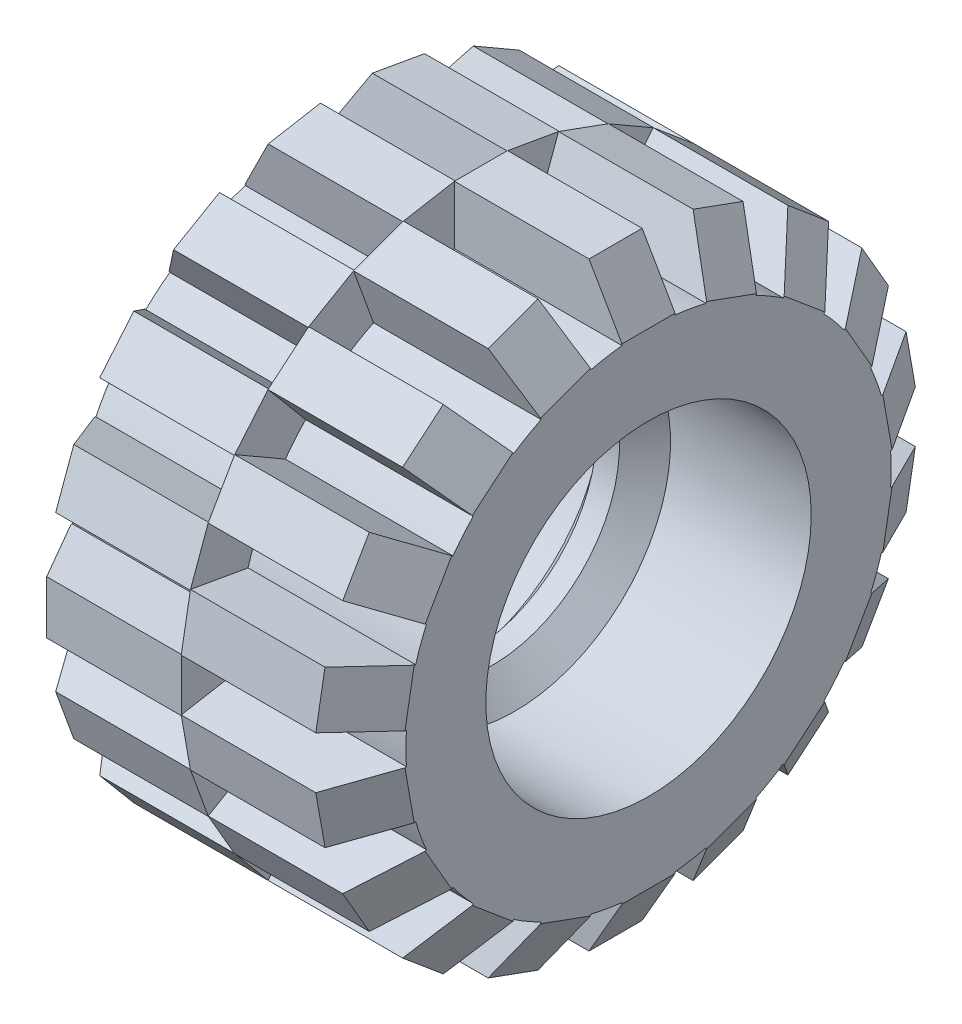
from build123d import *
from OCP.BRepFilletAPI import BRepFilletAPI_MakeChamfer

# Parameters (mm, degrees)
EXTRUDE1_DEPTH                = 5.87
EXTRUDE1_DEPTH_BACK           = 5.87
SKETCH1_R                     = 8.5
SKETCH1_R_2                   = 5.7
EXTRUDE2_START                = 7
SKETCH2_W                     = 5.87
SKETCH2_H                     = 1.86
EXTRUDE2_DEPTH                = 3.5
EXTRUDE3_START                = 7
SKETCH4_W                     = 5.87
SKETCH4_H                     = 1.86
EXTRUDE3_DEPTH                = 3.5
CHAMFER1_SIZE                 = 2
CHAMFER1_SIZE2                = 1.154700538
CIRPATTERN3_COUNT             = 18
CHAMFER1_OF_CIRPATTERN3_SIZE  = 2
CHAMFER1_OF_CIRPATTERN3_SIZE2 = 1.154700538


with BuildPart() as part:
    # Sketch1 → Extrude1 (new, two sides: drawn at the far end of the back side and taken through both)
    with BuildSketch(Plane(origin=(0, 0, 0), x_dir=(0, 0, -1), z_dir=(1, 0, 0)).offset(-EXTRUDE1_DEPTH_BACK)):
        Circle(SKETCH1_R)
        Circle(SKETCH1_R_2, mode=Mode.SUBTRACT)
    extrude(amount=EXTRUDE1_DEPTH + EXTRUDE1_DEPTH_BACK)

    # Sketch2 → Extrude2 (add)
    with BuildSketch(Plane(origin=(0, 0, 0), x_dir=(1, 0, 0), z_dir=(0, 1, 0)).offset(EXTRUDE2_START)):
        with Locations((2.935, 0)):
            Rectangle(SKETCH2_W, SKETCH2_H)
    extrude2 = extrude(amount=EXTRUDE2_DEPTH)

    # Sketch4 → Extrude3 (add)
    with BuildSketch(Plane.XY.offset(EXTRUDE3_START)):
        with Locations((-2.935, 0)):
            Rectangle(SKETCH4_W, SKETCH4_H)
    extrude3 = extrude(amount=EXTRUDE3_DEPTH)

    # Chamfer1: one chamfer whose edges measure the first distance from different faces: ONE call of the kernel's chamfer builder (chamfer() names one face for all edges)
    chamfer1_edges_1 = [part.edges().sort_by_distance(p)[0] for p in [
        (-5.87, 0, 10.5),
    ]]
    chamfer1_side_1 = [part.faces().sort_by_distance(p)[0] for p in [
        (-5.87, -8.232664961, -0.451731182),
    ]]
    chamfer1_edges_2 = [part.edges().sort_by_distance(p)[0] for p in [
        (5.87, 10.5, 0),
    ]]
    chamfer1_side_2 = [part.faces().sort_by_distance(p)[0] for p in [
        (5.87, -6.140795403, 5.501951039),
    ]]
    chamfer1 = BRepFilletAPI_MakeChamfer(part.part.solid().wrapped)
    for e in chamfer1_edges_1:
        chamfer1.Add(CHAMFER1_SIZE, CHAMFER1_SIZE2, e.wrapped, chamfer1_side_1[0].wrapped)  # the first distance lies on this face
    for e in chamfer1_edges_2:
        chamfer1.Add(CHAMFER1_SIZE, CHAMFER1_SIZE2, e.wrapped, chamfer1_side_2[0].wrapped)  # the first distance lies on this face
    add(Compound.cast(chamfer1.Shape()), mode=Mode.REPLACE)

    # CirPattern3: Extrude2, Extrude3 ×18 about axis
    cirpattern3_axis = Axis((-5.87, 0, 0), (1, 0, 0))
    add([extrude2.rotate(cirpattern3_axis, i * 360 / CIRPATTERN3_COUNT) for i in range(1, CIRPATTERN3_COUNT)])
    add([extrude3.rotate(cirpattern3_axis, i * 360 / CIRPATTERN3_COUNT) for i in range(1, CIRPATTERN3_COUNT)])

    # Chamfer1 of CirPattern3: one chamfer whose edges measure the first distance from different faces: ONE call of the kernel's chamfer builder (chamfer() names one face for all edges)
    chamfer1_of_cirpattern3_edges_1 = [part.edges().sort_by_distance(p)[0] for p in [
        (-5.87, -3.591211505, 9.866772518),
    ]]
    chamfer1_of_cirpattern3_side_1 = [part.faces().sort_by_distance(p)[0] for p in [
        (-5.87, -7.581673349, -3.240225708),
    ]]
    chamfer1_of_cirpattern3_edges_2 = [part.edges().sort_by_distance(p)[0] for p in [
        (5.87, 9.866772518, 3.591211505),
    ]]
    chamfer1_of_cirpattern3_side_2 = [part.faces().sort_by_distance(p)[0] for p in [
        (5.87, -7.652238209, 3.069867067),
    ]]
    chamfer1_of_cirpattern3_edges_3 = [part.edges().sort_by_distance(p)[0] for p in [
        (-5.87, -6.749269902, 8.043466653),
    ]]
    chamfer1_of_cirpattern3_side_3 = [part.faces().sort_by_distance(p)[0] for p in [
        (-5.87, -6.016220038, -5.637901193),
    ]]
    chamfer1_of_cirpattern3_edges_4 = [part.edges().sort_by_distance(p)[0] for p in [
        (5.87, 8.043466653, 6.749269902),
    ]]
    chamfer1_of_cirpattern3_side_4 = [part.faces().sort_by_distance(p)[0] for p in [
        (5.87, -8.240708152, 0.267511821),
    ]]
    chamfer1_of_cirpattern3_edges_5 = [part.edges().sort_by_distance(p)[0] for p in [
        (-5.87, -9.09326674, 5.25),
    ]]
    chamfer1_of_cirpattern3_side_5 = [part.faces().sort_by_distance(p)[0] for p in [
        (-5.87, -3.725121801, -7.355562588),
    ]]
    chamfer1_of_cirpattern3_edges_6 = [part.edges().sort_by_distance(p)[0] for p in [
        (5.87, 5.25, 9.09326674),
    ]]
    chamfer1_of_cirpattern3_side_6 = [part.faces().sort_by_distance(p)[0] for p in [
        (5.87, -7.835227071, -2.567109299),
    ]]
    chamfer1_of_cirpattern3_edges_7 = [part.edges().sort_by_distance(p)[0] for p in [
        (-5.87, -10.340481407, 1.823305866),
    ]]
    chamfer1_of_cirpattern3_side_7 = [part.faces().sort_by_distance(p)[0] for p in [
        (-5.87, -0.984718897, -8.186034578),
    ]]
    chamfer1_of_cirpattern3_edges_8 = [part.edges().sort_by_distance(p)[0] for p in [
        (5.87, 1.823305866, 10.340481407),
    ]]
    chamfer1_of_cirpattern3_side_8 = [part.faces().sort_by_distance(p)[0] for p in [
        (5.87, -6.484701971, -5.092099151),
    ]]
    chamfer1_of_cirpattern3_edges_9 = [part.edges().sort_by_distance(p)[0] for p in [
        (-5.87, -10.340481407, -1.823305866),
    ]]
    chamfer1_of_cirpattern3_side_9 = [part.faces().sort_by_distance(p)[0] for p in [
        (-5.87, 1.874455638, -8.029149985),
    ]]
    chamfer1_of_cirpattern3_edges_10 = [part.edges().sort_by_distance(p)[0] for p in [
        (5.87, -1.823305866, 10.340481407),
    ]]
    chamfer1_of_cirpattern3_side_10 = [part.faces().sort_by_distance(p)[0] for p in [
        (5.87, -4.352026108, -7.002906694),
    ]]
    chamfer1_of_cirpattern3_edges_11 = [part.edges().sort_by_distance(p)[0] for p in [
        (-5.87, -9.09326674, -5.25),
    ]]
    chamfer1_of_cirpattern3_side_11 = [part.faces().sort_by_distance(p)[0] for p in [
        (-5.87, 4.50754316, -6.903831406),
    ]]
    chamfer1_of_cirpattern3_edges_12 = [part.edges().sort_by_distance(p)[0] for p in [
        (5.87, -5.25, 9.09326674),
    ]]
    chamfer1_of_cirpattern3_side_12 = [part.faces().sort_by_distance(p)[0] for p in [
        (5.87, -1.694431668, -8.069060338),
    ]]
    chamfer1_of_cirpattern3_edges_13 = [part.edges().sort_by_distance(p)[0] for p in [
        (-5.87, -6.749269902, -8.043466653),
    ]]
    chamfer1_of_cirpattern3_side_13 = [part.faces().sort_by_distance(p)[0] for p in [
        (-5.87, 6.596954452, -4.945808869),
    ]]
    chamfer1_of_cirpattern3_edges_14 = [part.edges().sort_by_distance(p)[0] for p in [
        (5.87, -8.043466653, 6.749269902),
    ]]
    chamfer1_of_cirpattern3_side_14 = [part.faces().sort_by_distance(p)[0] for p in [
        (5.87, 1.167536238, -8.161966218),
    ]]
    chamfer1_of_cirpattern3_edges_15 = [part.edges().sort_by_distance(p)[0] for p in [
        (-5.87, -3.591211505, -9.866772518),
    ]]
    chamfer1_of_cirpattern3_side_15 = [part.faces().sort_by_distance(p)[0] for p in [
        (-5.87, 7.890675676, -2.391248791),
    ]]
    chamfer1_of_cirpattern3_edges_16 = [part.edges().sort_by_distance(p)[0] for p in [
        (5.87, -9.866772518, 3.591211505),
    ]]
    chamfer1_of_cirpattern3_side_16 = [part.faces().sort_by_distance(p)[0] for p in [
        (5.87, 3.888682043, -7.270418515),
    ]]
    chamfer1_of_cirpattern3_edges_17 = [part.edges().sort_by_distance(p)[0] for p in [
        (-5.87, 0, -10.5),
    ]]
    chamfer1_of_cirpattern3_side_17 = [part.faces().sort_by_distance(p)[0] for p in [
        (-5.87, 8.232664961, 0.451731182),
    ]]
    chamfer1_of_cirpattern3_edges_18 = [part.edges().sort_by_distance(p)[0] for p in [
        (5.87, -10.5, 0),
    ]]
    chamfer1_of_cirpattern3_side_18 = [part.faces().sort_by_distance(p)[0] for p in [
        (5.87, 6.140795403, -5.501951039),
    ]]
    chamfer1_of_cirpattern3_edges_19 = [part.edges().sort_by_distance(p)[0] for p in [
        (-5.87, 3.591211505, -9.866772518),
    ]]
    chamfer1_of_cirpattern3_side_19 = [part.faces().sort_by_distance(p)[0] for p in [
        (-5.87, 7.581673349, 3.240225708),
    ]]
    chamfer1_of_cirpattern3_edges_20 = [part.edges().sort_by_distance(p)[0] for p in [
        (5.87, -9.866772518, -3.591211505),
    ]]
    chamfer1_of_cirpattern3_side_20 = [part.faces().sort_by_distance(p)[0] for p in [
        (5.87, 7.652238209, -3.069867067),
    ]]
    chamfer1_of_cirpattern3_edges_21 = [part.edges().sort_by_distance(p)[0] for p in [
        (-5.87, 6.749269902, -8.043466653),
    ]]
    chamfer1_of_cirpattern3_side_21 = [part.faces().sort_by_distance(p)[0] for p in [
        (-5.87, 6.016220038, 5.637901193),
    ]]
    chamfer1_of_cirpattern3_edges_22 = [part.edges().sort_by_distance(p)[0] for p in [
        (5.87, -8.043466653, -6.749269902),
    ]]
    chamfer1_of_cirpattern3_side_22 = [part.faces().sort_by_distance(p)[0] for p in [
        (5.87, 8.240708152, -0.267511821),
    ]]
    chamfer1_of_cirpattern3_edges_23 = [part.edges().sort_by_distance(p)[0] for p in [
        (-5.87, 9.09326674, -5.25),
    ]]
    chamfer1_of_cirpattern3_side_23 = [part.faces().sort_by_distance(p)[0] for p in [
        (-5.87, 3.725121801, 7.355562588),
    ]]
    chamfer1_of_cirpattern3_edges_24 = [part.edges().sort_by_distance(p)[0] for p in [
        (5.87, -5.25, -9.09326674),
    ]]
    chamfer1_of_cirpattern3_side_24 = [part.faces().sort_by_distance(p)[0] for p in [
        (5.87, 7.835227071, 2.567109299),
    ]]
    chamfer1_of_cirpattern3_edges_25 = [part.edges().sort_by_distance(p)[0] for p in [
        (-5.87, 10.340481407, -1.823305866),
    ]]
    chamfer1_of_cirpattern3_side_25 = [part.faces().sort_by_distance(p)[0] for p in [
        (-5.87, 0.984718897, 8.186034578),
    ]]
    chamfer1_of_cirpattern3_edges_26 = [part.edges().sort_by_distance(p)[0] for p in [
        (5.87, -1.823305866, -10.340481407),
    ]]
    chamfer1_of_cirpattern3_side_26 = [part.faces().sort_by_distance(p)[0] for p in [
        (5.87, 6.484701971, 5.092099151),
    ]]
    chamfer1_of_cirpattern3_edges_27 = [part.edges().sort_by_distance(p)[0] for p in [
        (-5.87, 10.340481407, 1.823305866),
    ]]
    chamfer1_of_cirpattern3_side_27 = [part.faces().sort_by_distance(p)[0] for p in [
        (-5.87, -1.874455638, 8.029149985),
    ]]
    chamfer1_of_cirpattern3_edges_28 = [part.edges().sort_by_distance(p)[0] for p in [
        (5.87, 1.823305866, -10.340481407),
    ]]
    chamfer1_of_cirpattern3_side_28 = [part.faces().sort_by_distance(p)[0] for p in [
        (5.87, 4.352026108, 7.002906694),
    ]]
    chamfer1_of_cirpattern3_edges_29 = [part.edges().sort_by_distance(p)[0] for p in [
        (-5.87, 9.09326674, 5.25),
    ]]
    chamfer1_of_cirpattern3_side_29 = [part.faces().sort_by_distance(p)[0] for p in [
        (-5.87, -4.50754316, 6.903831406),
    ]]
    chamfer1_of_cirpattern3_edges_30 = [part.edges().sort_by_distance(p)[0] for p in [
        (5.87, 5.25, -9.09326674),
    ]]
    chamfer1_of_cirpattern3_side_30 = [part.faces().sort_by_distance(p)[0] for p in [
        (5.87, 1.694431668, 8.069060338),
    ]]
    chamfer1_of_cirpattern3_edges_31 = [part.edges().sort_by_distance(p)[0] for p in [
        (-5.87, 6.749269902, 8.043466653),
    ]]
    chamfer1_of_cirpattern3_side_31 = [part.faces().sort_by_distance(p)[0] for p in [
        (-5.87, -6.596954452, 4.945808869),
    ]]
    chamfer1_of_cirpattern3_edges_32 = [part.edges().sort_by_distance(p)[0] for p in [
        (5.87, 8.043466653, -6.749269902),
    ]]
    chamfer1_of_cirpattern3_side_32 = [part.faces().sort_by_distance(p)[0] for p in [
        (5.87, -1.167536238, 8.161966218),
    ]]
    chamfer1_of_cirpattern3_edges_33 = [part.edges().sort_by_distance(p)[0] for p in [
        (-5.87, 3.591211505, 9.866772518),
    ]]
    chamfer1_of_cirpattern3_side_33 = [part.faces().sort_by_distance(p)[0] for p in [
        (-5.87, -7.890675676, 2.391248791),
    ]]
    chamfer1_of_cirpattern3_edges_34 = [part.edges().sort_by_distance(p)[0] for p in [
        (5.87, 9.866772518, -3.591211505),
    ]]
    chamfer1_of_cirpattern3_side_34 = [part.faces().sort_by_distance(p)[0] for p in [
        (5.87, -3.888682043, 7.270418515),
    ]]
    chamfer1_of_cirpattern3 = BRepFilletAPI_MakeChamfer(part.part.solid().wrapped)
    for e in chamfer1_of_cirpattern3_edges_1:
        chamfer1_of_cirpattern3.Add(CHAMFER1_OF_CIRPATTERN3_SIZE, CHAMFER1_OF_CIRPATTERN3_SIZE2, e.wrapped, chamfer1_of_cirpattern3_side_1[0].wrapped)  # the first distance lies on this face
    for e in chamfer1_of_cirpattern3_edges_2:
        chamfer1_of_cirpattern3.Add(CHAMFER1_OF_CIRPATTERN3_SIZE, CHAMFER1_OF_CIRPATTERN3_SIZE2, e.wrapped, chamfer1_of_cirpattern3_side_2[0].wrapped)  # the first distance lies on this face
    for e in chamfer1_of_cirpattern3_edges_3:
        chamfer1_of_cirpattern3.Add(CHAMFER1_OF_CIRPATTERN3_SIZE, CHAMFER1_OF_CIRPATTERN3_SIZE2, e.wrapped, chamfer1_of_cirpattern3_side_3[0].wrapped)  # the first distance lies on this face
    for e in chamfer1_of_cirpattern3_edges_4:
        chamfer1_of_cirpattern3.Add(CHAMFER1_OF_CIRPATTERN3_SIZE, CHAMFER1_OF_CIRPATTERN3_SIZE2, e.wrapped, chamfer1_of_cirpattern3_side_4[0].wrapped)  # the first distance lies on this face
    for e in chamfer1_of_cirpattern3_edges_5:
        chamfer1_of_cirpattern3.Add(CHAMFER1_OF_CIRPATTERN3_SIZE, CHAMFER1_OF_CIRPATTERN3_SIZE2, e.wrapped, chamfer1_of_cirpattern3_side_5[0].wrapped)  # the first distance lies on this face
    for e in chamfer1_of_cirpattern3_edges_6:
        chamfer1_of_cirpattern3.Add(CHAMFER1_OF_CIRPATTERN3_SIZE, CHAMFER1_OF_CIRPATTERN3_SIZE2, e.wrapped, chamfer1_of_cirpattern3_side_6[0].wrapped)  # the first distance lies on this face
    for e in chamfer1_of_cirpattern3_edges_7:
        chamfer1_of_cirpattern3.Add(CHAMFER1_OF_CIRPATTERN3_SIZE, CHAMFER1_OF_CIRPATTERN3_SIZE2, e.wrapped, chamfer1_of_cirpattern3_side_7[0].wrapped)  # the first distance lies on this face
    for e in chamfer1_of_cirpattern3_edges_8:
        chamfer1_of_cirpattern3.Add(CHAMFER1_OF_CIRPATTERN3_SIZE, CHAMFER1_OF_CIRPATTERN3_SIZE2, e.wrapped, chamfer1_of_cirpattern3_side_8[0].wrapped)  # the first distance lies on this face
    for e in chamfer1_of_cirpattern3_edges_9:
        chamfer1_of_cirpattern3.Add(CHAMFER1_OF_CIRPATTERN3_SIZE, CHAMFER1_OF_CIRPATTERN3_SIZE2, e.wrapped, chamfer1_of_cirpattern3_side_9[0].wrapped)  # the first distance lies on this face
    for e in chamfer1_of_cirpattern3_edges_10:
        chamfer1_of_cirpattern3.Add(CHAMFER1_OF_CIRPATTERN3_SIZE, CHAMFER1_OF_CIRPATTERN3_SIZE2, e.wrapped, chamfer1_of_cirpattern3_side_10[0].wrapped)  # the first distance lies on this face
    for e in chamfer1_of_cirpattern3_edges_11:
        chamfer1_of_cirpattern3.Add(CHAMFER1_OF_CIRPATTERN3_SIZE, CHAMFER1_OF_CIRPATTERN3_SIZE2, e.wrapped, chamfer1_of_cirpattern3_side_11[0].wrapped)  # the first distance lies on this face
    for e in chamfer1_of_cirpattern3_edges_12:
        chamfer1_of_cirpattern3.Add(CHAMFER1_OF_CIRPATTERN3_SIZE, CHAMFER1_OF_CIRPATTERN3_SIZE2, e.wrapped, chamfer1_of_cirpattern3_side_12[0].wrapped)  # the first distance lies on this face
    for e in chamfer1_of_cirpattern3_edges_13:
        chamfer1_of_cirpattern3.Add(CHAMFER1_OF_CIRPATTERN3_SIZE, CHAMFER1_OF_CIRPATTERN3_SIZE2, e.wrapped, chamfer1_of_cirpattern3_side_13[0].wrapped)  # the first distance lies on this face
    for e in chamfer1_of_cirpattern3_edges_14:
        chamfer1_of_cirpattern3.Add(CHAMFER1_OF_CIRPATTERN3_SIZE, CHAMFER1_OF_CIRPATTERN3_SIZE2, e.wrapped, chamfer1_of_cirpattern3_side_14[0].wrapped)  # the first distance lies on this face
    for e in chamfer1_of_cirpattern3_edges_15:
        chamfer1_of_cirpattern3.Add(CHAMFER1_OF_CIRPATTERN3_SIZE, CHAMFER1_OF_CIRPATTERN3_SIZE2, e.wrapped, chamfer1_of_cirpattern3_side_15[0].wrapped)  # the first distance lies on this face
    for e in chamfer1_of_cirpattern3_edges_16:
        chamfer1_of_cirpattern3.Add(CHAMFER1_OF_CIRPATTERN3_SIZE, CHAMFER1_OF_CIRPATTERN3_SIZE2, e.wrapped, chamfer1_of_cirpattern3_side_16[0].wrapped)  # the first distance lies on this face
    for e in chamfer1_of_cirpattern3_edges_17:
        chamfer1_of_cirpattern3.Add(CHAMFER1_OF_CIRPATTERN3_SIZE, CHAMFER1_OF_CIRPATTERN3_SIZE2, e.wrapped, chamfer1_of_cirpattern3_side_17[0].wrapped)  # the first distance lies on this face
    for e in chamfer1_of_cirpattern3_edges_18:
        chamfer1_of_cirpattern3.Add(CHAMFER1_OF_CIRPATTERN3_SIZE, CHAMFER1_OF_CIRPATTERN3_SIZE2, e.wrapped, chamfer1_of_cirpattern3_side_18[0].wrapped)  # the first distance lies on this face
    for e in chamfer1_of_cirpattern3_edges_19:
        chamfer1_of_cirpattern3.Add(CHAMFER1_OF_CIRPATTERN3_SIZE, CHAMFER1_OF_CIRPATTERN3_SIZE2, e.wrapped, chamfer1_of_cirpattern3_side_19[0].wrapped)  # the first distance lies on this face
    for e in chamfer1_of_cirpattern3_edges_20:
        chamfer1_of_cirpattern3.Add(CHAMFER1_OF_CIRPATTERN3_SIZE, CHAMFER1_OF_CIRPATTERN3_SIZE2, e.wrapped, chamfer1_of_cirpattern3_side_20[0].wrapped)  # the first distance lies on this face
    for e in chamfer1_of_cirpattern3_edges_21:
        chamfer1_of_cirpattern3.Add(CHAMFER1_OF_CIRPATTERN3_SIZE, CHAMFER1_OF_CIRPATTERN3_SIZE2, e.wrapped, chamfer1_of_cirpattern3_side_21[0].wrapped)  # the first distance lies on this face
    for e in chamfer1_of_cirpattern3_edges_22:
        chamfer1_of_cirpattern3.Add(CHAMFER1_OF_CIRPATTERN3_SIZE, CHAMFER1_OF_CIRPATTERN3_SIZE2, e.wrapped, chamfer1_of_cirpattern3_side_22[0].wrapped)  # the first distance lies on this face
    for e in chamfer1_of_cirpattern3_edges_23:
        chamfer1_of_cirpattern3.Add(CHAMFER1_OF_CIRPATTERN3_SIZE, CHAMFER1_OF_CIRPATTERN3_SIZE2, e.wrapped, chamfer1_of_cirpattern3_side_23[0].wrapped)  # the first distance lies on this face
    for e in chamfer1_of_cirpattern3_edges_24:
        chamfer1_of_cirpattern3.Add(CHAMFER1_OF_CIRPATTERN3_SIZE, CHAMFER1_OF_CIRPATTERN3_SIZE2, e.wrapped, chamfer1_of_cirpattern3_side_24[0].wrapped)  # the first distance lies on this face
    for e in chamfer1_of_cirpattern3_edges_25:
        chamfer1_of_cirpattern3.Add(CHAMFER1_OF_CIRPATTERN3_SIZE, CHAMFER1_OF_CIRPATTERN3_SIZE2, e.wrapped, chamfer1_of_cirpattern3_side_25[0].wrapped)  # the first distance lies on this face
    for e in chamfer1_of_cirpattern3_edges_26:
        chamfer1_of_cirpattern3.Add(CHAMFER1_OF_CIRPATTERN3_SIZE, CHAMFER1_OF_CIRPATTERN3_SIZE2, e.wrapped, chamfer1_of_cirpattern3_side_26[0].wrapped)  # the first distance lies on this face
    for e in chamfer1_of_cirpattern3_edges_27:
        chamfer1_of_cirpattern3.Add(CHAMFER1_OF_CIRPATTERN3_SIZE, CHAMFER1_OF_CIRPATTERN3_SIZE2, e.wrapped, chamfer1_of_cirpattern3_side_27[0].wrapped)  # the first distance lies on this face
    for e in chamfer1_of_cirpattern3_edges_28:
        chamfer1_of_cirpattern3.Add(CHAMFER1_OF_CIRPATTERN3_SIZE, CHAMFER1_OF_CIRPATTERN3_SIZE2, e.wrapped, chamfer1_of_cirpattern3_side_28[0].wrapped)  # the first distance lies on this face
    for e in chamfer1_of_cirpattern3_edges_29:
        chamfer1_of_cirpattern3.Add(CHAMFER1_OF_CIRPATTERN3_SIZE, CHAMFER1_OF_CIRPATTERN3_SIZE2, e.wrapped, chamfer1_of_cirpattern3_side_29[0].wrapped)  # the first distance lies on this face
    for e in chamfer1_of_cirpattern3_edges_30:
        chamfer1_of_cirpattern3.Add(CHAMFER1_OF_CIRPATTERN3_SIZE, CHAMFER1_OF_CIRPATTERN3_SIZE2, e.wrapped, chamfer1_of_cirpattern3_side_30[0].wrapped)  # the first distance lies on this face
    for e in chamfer1_of_cirpattern3_edges_31:
        chamfer1_of_cirpattern3.Add(CHAMFER1_OF_CIRPATTERN3_SIZE, CHAMFER1_OF_CIRPATTERN3_SIZE2, e.wrapped, chamfer1_of_cirpattern3_side_31[0].wrapped)  # the first distance lies on this face
    for e in chamfer1_of_cirpattern3_edges_32:
        chamfer1_of_cirpattern3.Add(CHAMFER1_OF_CIRPATTERN3_SIZE, CHAMFER1_OF_CIRPATTERN3_SIZE2, e.wrapped, chamfer1_of_cirpattern3_side_32[0].wrapped)  # the first distance lies on this face
    for e in chamfer1_of_cirpattern3_edges_33:
        chamfer1_of_cirpattern3.Add(CHAMFER1_OF_CIRPATTERN3_SIZE, CHAMFER1_OF_CIRPATTERN3_SIZE2, e.wrapped, chamfer1_of_cirpattern3_side_33[0].wrapped)  # the first distance lies on this face
    for e in chamfer1_of_cirpattern3_edges_34:
        chamfer1_of_cirpattern3.Add(CHAMFER1_OF_CIRPATTERN3_SIZE, CHAMFER1_OF_CIRPATTERN3_SIZE2, e.wrapped, chamfer1_of_cirpattern3_side_34[0].wrapped)  # the first distance lies on this face
    add(Compound.cast(chamfer1_of_cirpattern3.Shape()), mode=Mode.REPLACE)


with BuildPart() as body_2:
    # Sketch6 → Revolve1 (revolve)
    with BuildSketch(Plane.XY):
        Polygon((-0.4, 4.452191556), (0.4, 4.452191556), (1.19, 5.452191556), (-1.19, 5.452191556), align=None)
    revolve(axis=Axis((-5.87, 0, 0), (1, 0, 0)))


solid = Compound([part.part, body_2.part])
